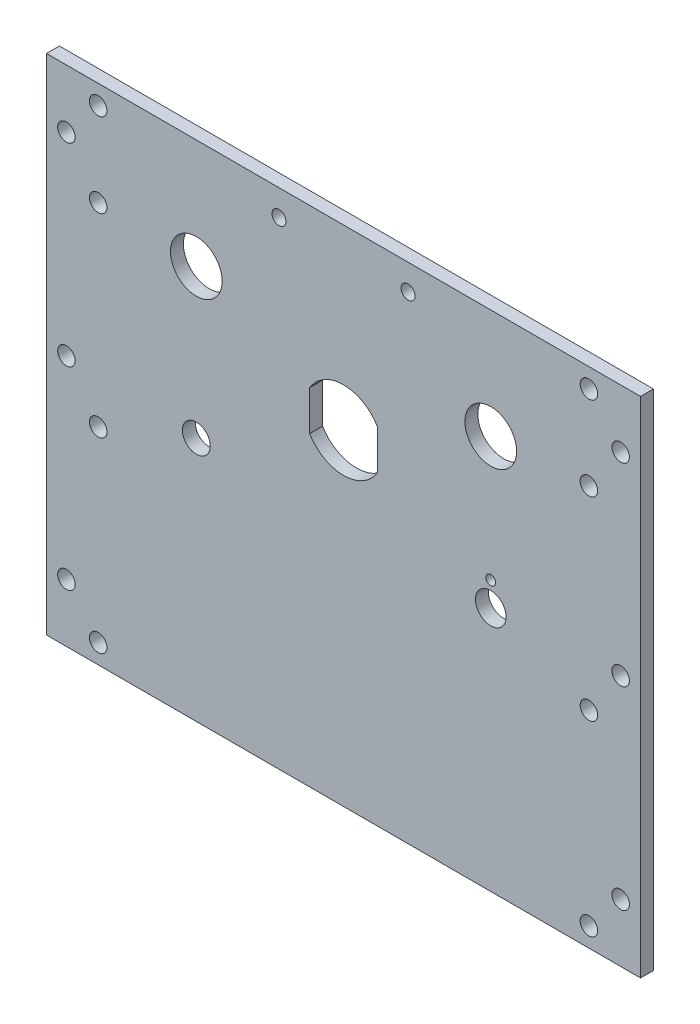
from build123d import *

# Parameters (mm, degrees)
SKETCH1_W             = 146.05
SKETCH1_H             = 123.825
BOSS_EXTRUDE1_DEPTH   = 3.175
F_6_CLEARANCE_HOLE1_D = 4.3053
SKETCH4_R             = 6.35
SKETCH4_R_2           = 3.7703125
SKETCH4_R_3           = 3.429
SKETCH4_R_4           = 1.190625
CUT_EXTRUDE1_DEPTH    = 4.175
F_4_CLEARANCE_HOLE1_D = 3.4544


with BuildPart() as part:
    # Sketch1 → Boss-Extrude1 (new body)
    with BuildSketch(Plane.XY):
        with Locations((-73.025, 61.9125)):
            Rectangle(SKETCH1_W, SKETCH1_H)
    extrude(amount=-BOSS_EXTRUDE1_DEPTH)

    # #6 Clearance Hole1 (through all)
    with Locations(Plane(origin=(0, 0, -3.175), x_dir=(-1, 0, 0), z_dir=(0, 0, -1))):
        with Locations((12.7, 119.0625), (133.35, 119.0625), (141.1605, 109.5375), (133.35, 98.425), (141.1605, 61.9125), (133.35, 50.673), (133.35, 4.7625), (12.7, 4.7625), (12.7, 50.673), (12.7, 98.425), (4.8895, 109.5375), (141.1605, 14.2875), (4.8895, 14.2875), (4.8895, 61.9125)):
            Hole(F_6_CLEARANCE_HOLE1_D / 2)

    # Sketch4 → Cut-Extrude1 (cut, through all)
    with BuildSketch(Plane(origin=(0, 0, -3.175), x_dir=(-1, 0, 0), z_dir=(0, 0, -1))):
        with Locations((36.83, 96.901)):
            Circle(SKETCH4_R)
        with Locations((36.83, 60.325)):
            Circle(SKETCH4_R_2)
        with Locations((109.22, 60.325)):
            Circle(SKETCH4_R_3)
        with Locations((109.22, 96.901)):
            Circle(SKETCH4_R)
        with Locations((36.830000026, 66.325)):
            Circle(SKETCH4_R_4)
        with BuildLine():
            Line((81.3435, 85.032269324), (81.3435, 75.241730676))
            ThreePointArc((81.3435, 75.241730676), (73.025, 70.485), (64.7065, 75.241730676))
            Line((64.7065, 75.241730676), (64.7065, 85.032269324))
            ThreePointArc((64.7065, 85.032269324), (73.025, 89.789), (81.3435, 85.032269324))
        make_face()
    extrude(amount=-CUT_EXTRUDE1_DEPTH, mode=Mode.SUBTRACT)

    # #4 Clearance Hole1 (through all)
    with Locations(Plane.XY):
        with Locations((-88.9, 117.475), (-57.15, 117.475)):
            Hole(F_4_CLEARANCE_HOLE1_D / 2)


solid = part.part
